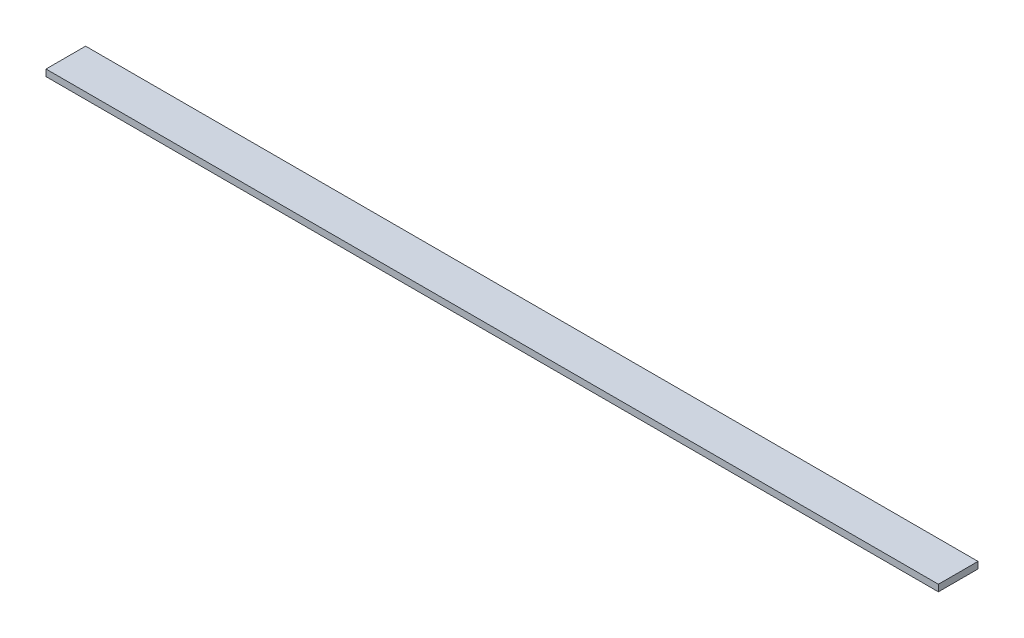
from build123d import *

# Parameters (mm, degrees)
SKETCH7_W           = 429.26
SKETCH7_H           = 19.05
BOSS_EXTRUDE5_DEPTH = 3.175


with BuildPart() as part:
    # Sketch7 → Boss-Extrude5 (new body)
    with BuildSketch(Plane(origin=(0, 0, 0), x_dir=(1, 0, 0), z_dir=(0, 1, 0))):
        with Locations((-214.63, -9.525)):
            Rectangle(SKETCH7_W, SKETCH7_H)
    extrude(amount=BOSS_EXTRUDE5_DEPTH)


solid = part.part
